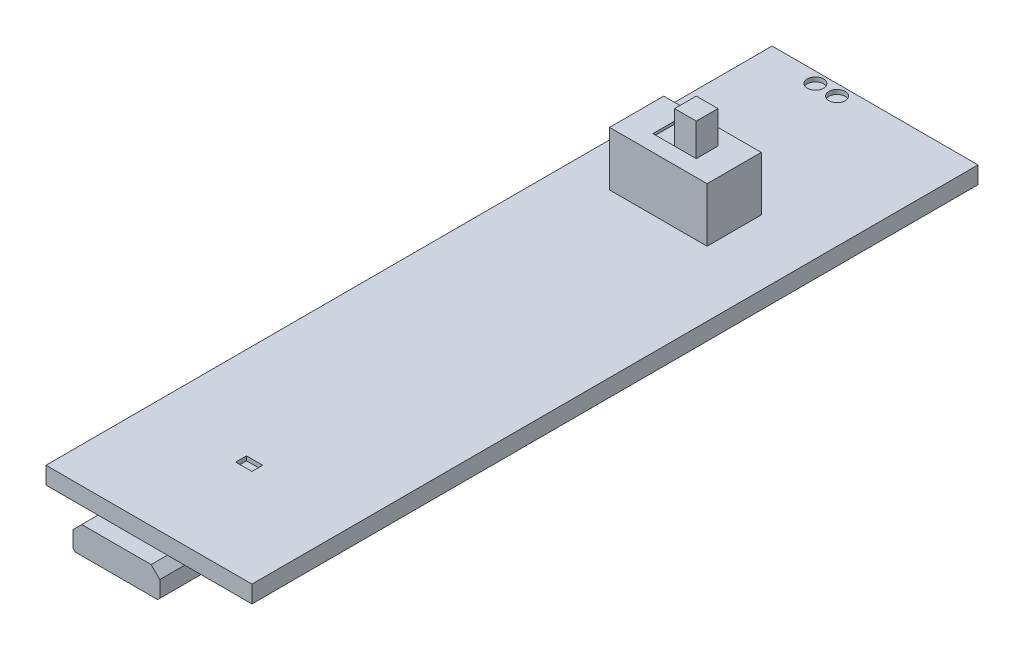
from build123d import *

# Parameters (mm, degrees)
SKETCH1_W                = 19
SKETCH1_H                = 67
BOSS_EXTRUDE1_DEPTH      = 0.79375
SKETCH3_W                = 9
SKETCH3_H                = 5
BOSS_EXTRUDE2_DEPTH      = 5
SKETCH4_W                = 2
SKETCH4_H                = 2
CUT_EXTRUDE2_DEPTH       = 0.25
SKETCH4_3_W              = 2
SKETCH4_3_H              = 2
BOSS_EXTRUDE3_DEPTH      = 3
BOSS_EXTRUDE3_DEPTH_BACK = 6.5875
SKETCH5_W                = 8
SKETCH5_H                = 2.5
BOSS_EXTRUDE4_DEPTH      = 6
SKETCH2_R                = 0.75
SKETCH2_W                = 1.5
SKETCH2_H                = 1
CUT_EXTRUDE1_DEPTH       = 0.396875
CHAMFER1_SIZE            = 0.8
CHAMFER2_SIZE            = 0.2


with BuildPart() as part:
    # Sketch1 → Boss-Extrude1 (new body, symmetric)
    with BuildSketch(Plane(origin=(0, 0, 0), x_dir=(1, 0, 0), z_dir=(0, 1, 0))):
        Rectangle(SKETCH1_W, SKETCH1_H)
    extrude(amount=BOSS_EXTRUDE1_DEPTH, both=True)

    # Sketch3 → Boss-Extrude2 (add)
    with BuildSketch(Plane(origin=(0, 0.79375, 0), x_dir=(1, 0, 0), z_dir=(0, 1, 0))):
        with Locations((-1, 17)):
            Rectangle(SKETCH3_W, SKETCH3_H)
    extrude(amount=BOSS_EXTRUDE2_DEPTH)

    # Sketch4 → Cut-Extrude2 (cut)
    with BuildSketch(Plane(origin=(0, 5.79375, 0), x_dir=(1, 0, 0), z_dir=(0, 1, 0))):
        with Locations((-2, 17)):
            Rectangle(SKETCH4_W, SKETCH4_H)
        with Locations((0, 17)):
            Rectangle(SKETCH4_W, SKETCH4_H)
    extrude(amount=-CUT_EXTRUDE2_DEPTH, mode=Mode.SUBTRACT)

    # Sketch4_3 → Boss-Extrude3 (add, two sides)
    with BuildSketch(Plane(origin=(0, 5.79375, 0), x_dir=(1, 0, 0), z_dir=(0, 1, 0))) as boss_extrude3_sk:
        with Locations((0, 17)):
            Rectangle(SKETCH4_3_W, SKETCH4_3_H)
    extrude(amount=BOSS_EXTRUDE3_DEPTH)
    extrude(boss_extrude3_sk.sketch, amount=-BOSS_EXTRUDE3_DEPTH_BACK)

    # Sketch2 → Cut-Extrude1 (cut)
    with BuildSketch(Plane(origin=(0, 0.79375, 0), x_dir=(1, 0, 0), z_dir=(0, 1, 0))):
        with Locations((-4.5, 32.5)):
            Circle(SKETCH2_R)
        with Locations((-2.5, 32.5)):
            Circle(SKETCH2_R)
        with Locations((-0.25, -24)):
            Rectangle(SKETCH2_W, SKETCH2_H)
    extrude(amount=-CUT_EXTRUDE1_DEPTH, mode=Mode.SUBTRACT)


with BuildPart() as body_2:
    # Sketch5 → Boss-Extrude4 (new body)
    with BuildSketch(Plane.XY.offset(35)):
        with Locations((-1.5, -2.04375)):
            Rectangle(SKETCH5_W, SKETCH5_H)
    extrude(amount=-BOSS_EXTRUDE4_DEPTH)

    # Chamfer1
    chamfer1_edges = [body_2.edges().sort_by_distance(p)[0] for p in [
        (-5.5, -0.79375, 32),
        (2.5, -0.79375, 32),
    ]]
    chamfer(chamfer1_edges, length=CHAMFER1_SIZE)

    # Chamfer2
    chamfer2_edges = [body_2.edges().sort_by_distance(p)[0] for p in [
        (2.5, -3.29375, 32),
        (-5.5, -3.29375, 32),
    ]]
    chamfer(chamfer2_edges, length=CHAMFER2_SIZE)


solid = Compound([part.part, body_2.part])
